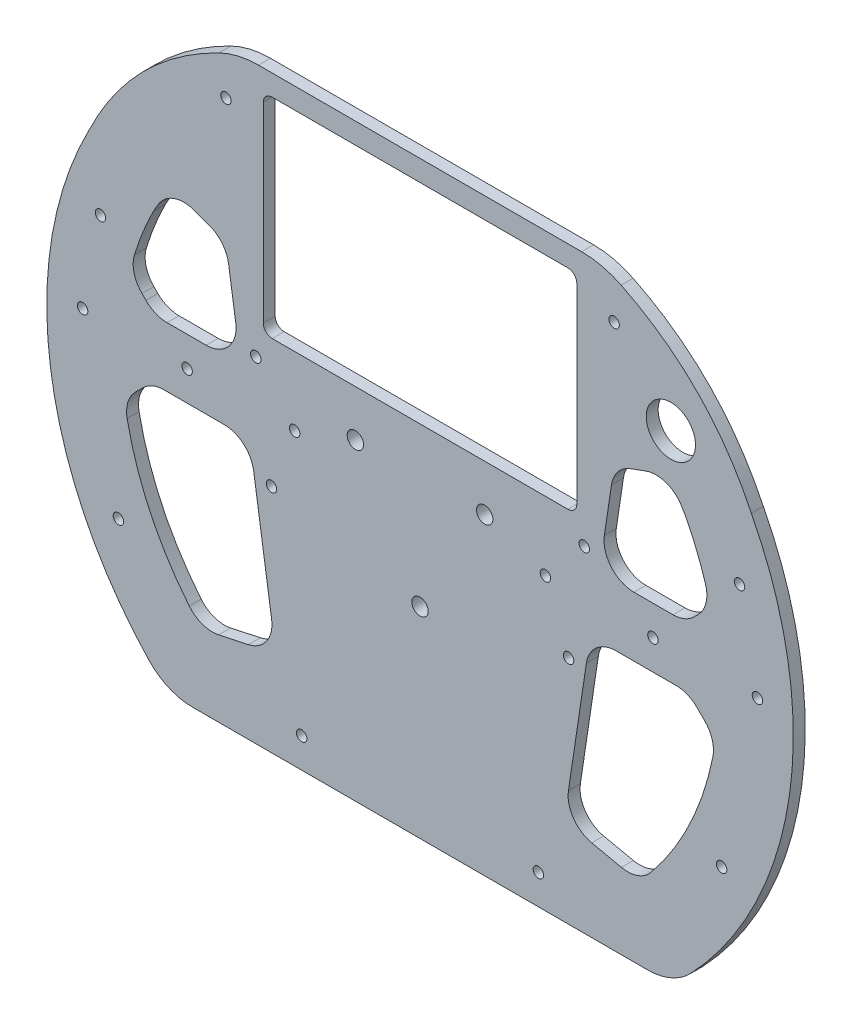
from build123d import *

# Parameters (mm, degrees)
EXTRUDE_1_DEPTH     = 4
EXTRUDE_3_DEPTH     = 4
FILLET_1_R          = 10
FILLET_2_R          = 10
FILLET_3_R          = 10
FILLET_4_R          = 20
SKETCH_11_W         = 105
SKETCH_11_H         = 70
CUT_EXTRUDE_1_DEPTH = 10
FILLET_7_R          = 3
EXTRUDE_4_DEPTH     = 4
FILLET_8_R          = 30
SKETCH_13_R         = 1.75
CUT_EXTRUDE_2_DEPTH = 10
SKETCH_14_R         = 1.75
CUT_EXTRUDE_3_DEPTH = 10
SKETCH_15_R         = 2.75
CUT_EXTRUDE_4_DEPTH = 10
SKETCH_16_R         = 8.25
CUT_EXTRUDE_5_DEPTH = 10
SKETCH_18_R         = 1.75
CUT_EXTRUDE_6_DEPTH = 10


with BuildPart() as part:
    # ｽｹｯﾁ8 → ﾎﾞｽ - 押し出し1 (new body)
    with BuildSketch(Plane.XY):
        with BuildLine():
            Line((-110.970347899, 57.537656255), (-92.986343016, 83.537656255))
            Line((-92.986343016, 83.537656255), (-60.5, 105))
            Line((-60.5, 105), (60.5, 105))
            Line((60.5, 105), (92.986343016, 83.537656255))
            Line((92.986343016, 83.537656255), (110.970347899, 57.537656255))
            ThreePointArc((110.970347899, 57.537656255), (123.070502428, -21.878103945), (84.341344527, -92.257994794))
            Line((84.341344527, -92.257994794), (-84.341344527, -92.257994794))
            ThreePointArc((-84.341344527, -92.257994794), (-123.070502428, -21.878103945), (-110.970347899, 57.537656255))
        make_face()
        with BuildLine():
            Line((-89.302855497, 45), (-83.516465442, 55))
            Line((-83.516465442, 55), (-65, 48.260557735))
            Line((-65, 48.260557735), (-60, 15))
            Line((-60, 15), (-98.868599666, 15))
            ThreePointArc((-98.868599666, 15), (-95.273942579, 30.378872023), (-89.302855497, 45))
        make_face(mode=Mode.SUBTRACT)
        with BuildLine():
            Line((89.302855497, 45), (83.516465442, 55))
            Line((83.516465442, 55), (65, 48.260557735))
            Line((65, 48.260557735), (60, 15))
            Line((60, 15), (98.868599666, 15))
            ThreePointArc((98.868599666, 15), (95.273942579, 30.378872023), (89.302855497, 45))
        make_face(mode=Mode.SUBTRACT)
        with BuildLine():
            Line((-56.993435865, -5), (-48.304740393, -62.798171475))
            Line((-48.304740393, -62.798171475), (-73.194926437, -68.13591376))
            ThreePointArc((-73.194926437, -68.13591376), (-92.113131484, -38.9251976), (-99.874921777, -5))
            Line((-99.874921777, -5), (-56.993435865, -5))
        make_face(mode=Mode.SUBTRACT)
        with BuildLine():
            Line((56.993435865, -5), (48.304740393, -62.798171475))
            Line((48.304740393, -62.798171475), (73.194926437, -68.13591376))
            ThreePointArc((73.194926437, -68.13591376), (92.113131484, -38.9251976), (99.874921777, -5))
            Line((99.874921777, -5), (56.993435865, -5))
        make_face(mode=Mode.SUBTRACT)
    extrude(amount=-EXTRUDE_1_DEPTH)

    # ｽｹｯﾁ10 → ﾎﾞｽ - 押し出し3 (add)
    with BuildSketch(Plane.XY):
        Polygon((-99.874921777, -15), (-89.874921777, -5), (-99.874921777, -5), align=None)
        Polygon((-98.868599666, 15), (-88.868599666, 15), (-98.868599666, 25), align=None)
        Polygon((88.868599666, 15), (98.868599666, 15), (98.868599666, 25), align=None)
        Polygon((89.874921777, -5), (99.874921777, -5), (99.874921777, -15), align=None)
    extrude(amount=-EXTRUDE_3_DEPTH)

    # ﾌｨﾚｯﾄ1
    fillet_1_edges = [part.edges().sort_by_distance(p)[0] for p in [
        (-97.232371907, 23.363772241, -2),
        (-88.868599666, 15, -2),
        (88.868599666, 15, -2),
        (97.232371907, 23.363772241, -2),
        (98.997711183, -14.122789405, -2),
        (89.874921777, -5, -2),
        (-48.304740393, -62.798171475, -2),
        (-73.194926437, -68.13591376, -2),
        (48.304740393, -62.798171475, -2),
        (73.194926437, -68.13591376, -2),
        (-98.997711183, -14.122789405, -2),
        (-89.874921777, -5, -2),
    ]]
    fillet(fillet_1_edges, radius=FILLET_1_R)

    # ﾌｨﾚｯﾄ2
    fillet_2_edges = [part.edges().sort_by_distance(p)[0] for p in [
        (-56.993435865, -5, -2),
        (-60, 15, -2),
        (56.993435865, -5, -2),
        (60, 15, -2),
    ]]
    fillet(fillet_2_edges, radius=FILLET_2_R)

    # ﾌｨﾚｯﾄ3
    fillet_3_edges = [part.edges().sort_by_distance(p)[0] for p in [
        (-65, 48.260557735, -2),
        (-83.516465442, 55, -2),
        (83.516465442, 55, -2),
        (65, 48.260557735, -2),
    ]]
    fillet(fillet_3_edges, radius=FILLET_3_R)

    # ﾌｨﾚｯﾄ4
    fillet_4_edges = [part.edges().sort_by_distance(p)[0] for p in [
        (84.341344527, -92.257994794, -2),
        (-84.341344527, -92.257994794, -2),
    ]]
    fillet(fillet_4_edges, radius=FILLET_4_R)

    # ｽｹｯﾁ11 → ｶｯﾄ - 押し出し1 (cut)
    with BuildSketch(Plane.XY):
        with Locations((0, 63)):
            Rectangle(SKETCH_11_W, SKETCH_11_H)
    extrude(amount=-CUT_EXTRUDE_1_DEPTH, mode=Mode.SUBTRACT)

    # ﾌｨﾚｯﾄ7
    fillet_7_edges = [part.edges().sort_by_distance(p)[0] for p in [
        (52.5, 98, -2),
        (52.5, 28, -2),
        (-52.5, 28, -2),
        (-52.5, 98, -2),
    ]]
    fillet(fillet_7_edges, radius=FILLET_7_R)

    # ｽｹｯﾁ12 → ﾎﾞｽ - 押し出し4 (add)
    with BuildSketch(Plane.XY):
        with BuildLine():
            add(Edge.make_bspline(
                [(-92.986343016, 83.537656255), (-79.595640691, 97.18270504), (-60.5, 105)],
                knots=[0.448106601, 0.448106601, 0.448106601, 1, 1, 1], degree=2))
            Line((-92.986343016, 83.537656255), (-60.5, 105))
        make_face()
        with BuildLine():
            add(Edge.make_bspline(
                [(-110.970347899, 57.537656255), (-103.858845057, 72.4586391), (-92.986343016, 83.537656255)],
                knots=[0, 0, 0, 0.448106601, 0.448106601, 0.448106601], degree=2))
            Line((-110.970347899, 57.537656255), (-92.986343016, 83.537656255))
        make_face()
        with BuildLine():
            add(Edge.make_bspline(
                [(92.986343016, 83.537656255), (79.595640691, 97.18270504), (60.5, 105)],
                knots=[0.448106601, 0.448106601, 0.448106601, 1, 1, 1], degree=2))
            Line((60.5, 105), (92.986343016, 83.537656255))
        make_face()
        with BuildLine():
            add(Edge.make_bspline(
                [(110.970347899, 57.537656255), (103.858845057, 72.4586391), (92.986343016, 83.537656255)],
                knots=[0, 0, 0, 0.448106601, 0.448106601, 0.448106601], degree=2))
            Line((92.986343016, 83.537656255), (110.970347899, 57.537656255))
        make_face()
    extrude(amount=-EXTRUDE_4_DEPTH)

    # ﾌｨﾚｯﾄ8
    fillet_8_edges = [part.edges().sort_by_distance(p)[0] for p in [
        (-60.5, 105, -2),
        (60.5, 105, -2),
    ]]
    fillet(fillet_8_edges, radius=FILLET_8_R)

    # ｽｹｯﾁ13 → ｶｯﾄ - 押し出し2 (cut)
    with BuildSketch(Plane.XY):
        with Locations((107, 35)):
            Circle(SKETCH_13_R)
        with Locations((113, 5)):
            Circle(SKETCH_13_R)
        with Locations((78, 5)):
            Circle(SKETCH_13_R)
        with Locations((101, -50)):
            Circle(SKETCH_13_R)
        with Locations((-101, -50)):
            Circle(SKETCH_13_R)
        with Locations((-78, 5)):
            Circle(SKETCH_13_R)
        with Locations((-113, 5)):
            Circle(SKETCH_13_R)
        with Locations((-107, 35)):
            Circle(SKETCH_13_R)
    extrude(amount=-CUT_EXTRUDE_2_DEPTH, mode=Mode.SUBTRACT)

    # ｽｹｯﾁ14 → ｶｯﾄ - 押し出し3 (cut)
    with BuildSketch(Plane.XY):
        with Locations((-65, 90)):
            Circle(SKETCH_14_R)
        with Locations((-55, 20)):
            Circle(SKETCH_14_R)
        with Locations((-49.738512764, -15)):
            Circle(SKETCH_14_R)
        with Locations((-39.627739016, -82.257994794)):
            Circle(SKETCH_14_R)
        with Locations((65, 90)):
            Circle(SKETCH_14_R)
        with Locations((55, 20)):
            Circle(SKETCH_14_R)
        with Locations((49.738512764, -15)):
            Circle(SKETCH_14_R)
        with Locations((39.627739016, -82.257994794)):
            Circle(SKETCH_14_R)
    extrude(amount=-CUT_EXTRUDE_3_DEPTH, mode=Mode.SUBTRACT)

    # ｽｹｯﾁ15 → ｶｯﾄ - 押し出し4 (cut)
    with BuildSketch(Plane.XY):
        with Locations((-21.650635095, 12.5)):
            Circle(SKETCH_15_R)
        with Locations((21.650635095, 12.5)):
            Circle(SKETCH_15_R)
        with Locations((0, -25)):
            Circle(SKETCH_15_R)
    extrude(amount=-CUT_EXTRUDE_4_DEPTH, mode=Mode.SUBTRACT)

    # ｽｹｯﾁ16 → ｶｯﾄ - 押し出し5 (cut)
    with BuildSketch(Plane.XY):
        with Locations((84, 68)):
            Circle(SKETCH_16_R)
    extrude(amount=-CUT_EXTRUDE_5_DEPTH, mode=Mode.SUBTRACT)

    # ｽｹｯﾁ18 → ｶｯﾄ - 押し出し6 (cut)
    with BuildSketch(Plane.XY):
        with Locations((-42, 5)):
            Circle(SKETCH_18_R)
        with Locations((42, 5)):
            Circle(SKETCH_18_R)
    extrude(amount=-CUT_EXTRUDE_6_DEPTH, mode=Mode.SUBTRACT)


solid = part.part
